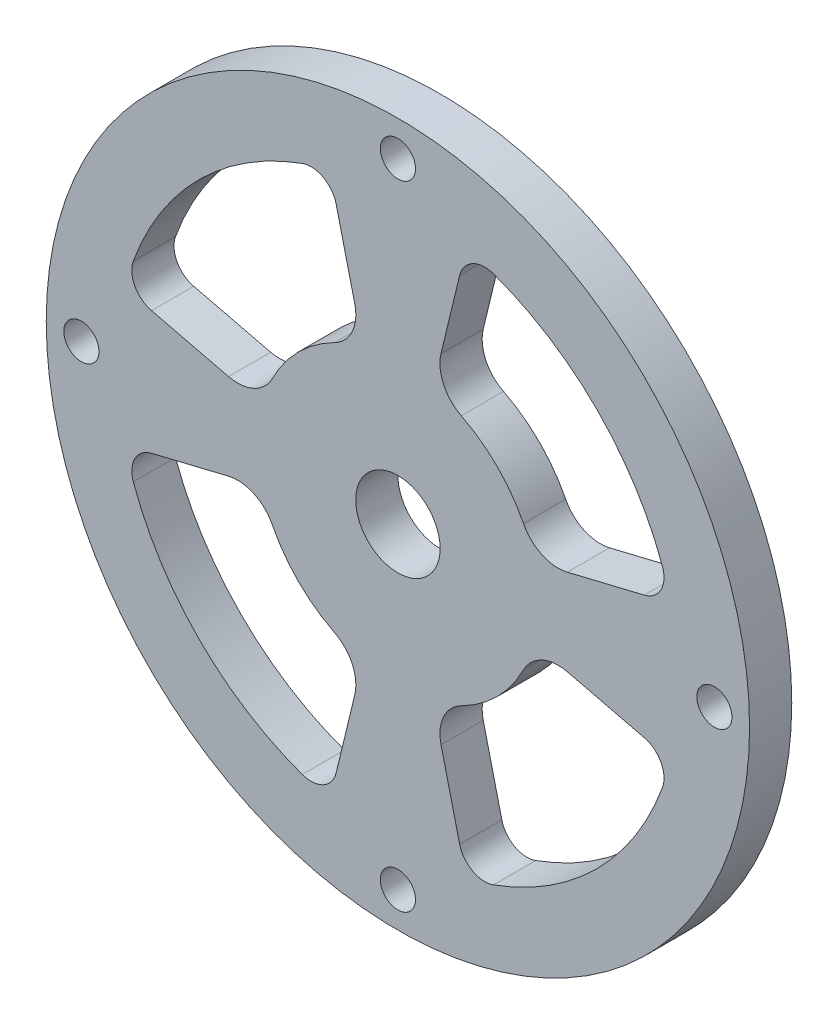
from build123d import *

# Parameters (mm, degrees)
SKETCH1_R           = 25
SKETCH1_R_2         = 1.25
SKETCH1_R_3         = 3
BOSS_EXTRUDE1_DEPTH = 3


with BuildPart() as part:
    # Sketch1 → Boss-Extrude1 (new body)
    with BuildSketch(Plane.XY):
        Circle(SKETCH1_R)
        with Locations((0, 22.5)):
            Circle(SKETCH1_R_2, mode=Mode.SUBTRACT)
        Circle(SKETCH1_R_3, mode=Mode.SUBTRACT)
        with Locations((22.5, 0)):
            Circle(SKETCH1_R_2, mode=Mode.SUBTRACT)
        with Locations((0, -22.5)):
            Circle(SKETCH1_R_2, mode=Mode.SUBTRACT)
        with Locations((-22.5, 0)):
            Circle(SKETCH1_R_2, mode=Mode.SUBTRACT)
        with BuildLine():
            Line((4.39039635, 17.512781765), (3.066480056, 12.042499157))
            ThreePointArc((3.066480056, 12.042499157), (3.243806018, 10.234010462), (4.506349736, 8.927083066))
            ThreePointArc((4.506349736, 8.927083066), (7.071067812, 7.071067812), (8.927083066, 4.506349736))
            ThreePointArc((8.927083066, 4.506349736), (10.234010462, 3.243806018), (12.042499157, 3.066480056))
            Line((12.042499157, 3.066480056), (17.512781765, 4.39039635))
            ThreePointArc((17.512781765, 4.39039635), (18.69880908, 5.306187253), (18.808282105, 6.800626756))
            ThreePointArc((18.808282105, 6.800626756), (14.142135624, 14.142135624), (6.800626756, 18.808282105))
            ThreePointArc((6.800626756, 18.808282105), (5.306187253, 18.69880908), (4.39039635, 17.512781765))
        make_face(mode=Mode.SUBTRACT)
        with BuildLine():
            Line((4.39039635, -17.512781765), (3.066480056, -12.042499157))
            ThreePointArc((3.066480056, -12.042499157), (3.243806018, -10.234010462), (4.506349736, -8.927083066))
            ThreePointArc((4.506349736, -8.927083066), (7.071067812, -7.071067812), (8.927083066, -4.506349736))
            ThreePointArc((8.927083066, -4.506349736), (10.234010462, -3.243806018), (12.042499157, -3.066480056))
            Line((12.042499157, -3.066480056), (17.512781765, -4.39039635))
            ThreePointArc((17.512781765, -4.39039635), (18.69880908, -5.306187253), (18.808282105, -6.800626756))
            ThreePointArc((18.808282105, -6.800626756), (14.142135624, -14.142135624), (6.800626756, -18.808282105))
            ThreePointArc((6.800626756, -18.808282105), (5.306187253, -18.69880908), (4.39039635, -17.512781765))
        make_face(mode=Mode.SUBTRACT)
        with BuildLine():
            Line((-17.512781765, -4.39039635), (-12.042499157, -3.066480056))
            ThreePointArc((-12.042499157, -3.066480056), (-10.234010462, -3.243806018), (-8.927083066, -4.506349736))
            ThreePointArc((-8.927083066, -4.506349736), (-7.071067812, -7.071067812), (-4.506349736, -8.927083066))
            ThreePointArc((-4.506349736, -8.927083066), (-3.243806018, -10.234010462), (-3.066480056, -12.042499157))
            Line((-3.066480056, -12.042499157), (-4.39039635, -17.512781765))
            ThreePointArc((-4.39039635, -17.512781765), (-5.306187253, -18.69880908), (-6.800626756, -18.808282105))
            ThreePointArc((-6.800626756, -18.808282105), (-14.142135624, -14.142135624), (-18.808282105, -6.800626756))
            ThreePointArc((-18.808282105, -6.800626756), (-18.69880908, -5.306187253), (-17.512781765, -4.39039635))
        make_face(mode=Mode.SUBTRACT)
        with BuildLine():
            Line((-4.39039635, 17.512781765), (-3.066480056, 12.042499157))
            ThreePointArc((-3.066480056, 12.042499157), (-3.243806018, 10.234010462), (-4.506349736, 8.927083066))
            ThreePointArc((-4.506349736, 8.927083066), (-7.071067812, 7.071067812), (-8.927083066, 4.506349736))
            ThreePointArc((-8.927083066, 4.506349736), (-10.234010462, 3.243806018), (-12.042499157, 3.066480056))
            Line((-12.042499157, 3.066480056), (-17.512781765, 4.39039635))
            ThreePointArc((-17.512781765, 4.39039635), (-18.69880908, 5.306187253), (-18.808282105, 6.800626756))
            ThreePointArc((-18.808282105, 6.800626756), (-14.142135624, 14.142135624), (-6.800626756, 18.808282105))
            ThreePointArc((-6.800626756, 18.808282105), (-5.306187253, 18.69880908), (-4.39039635, 17.512781765))
        make_face(mode=Mode.SUBTRACT)
    extrude(amount=BOSS_EXTRUDE1_DEPTH)


solid = part.part
